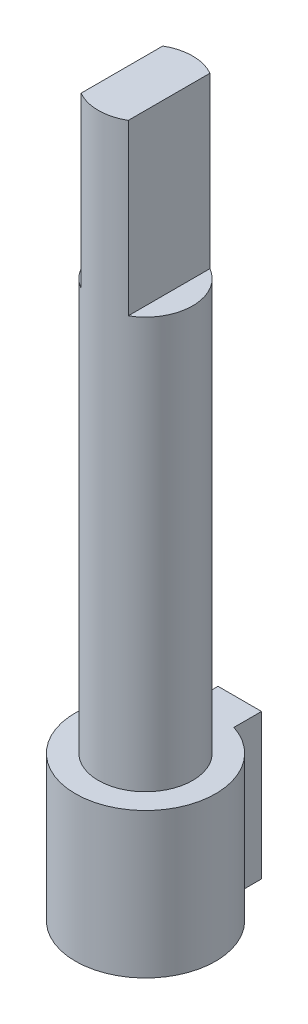
from build123d import *

# Parameters (mm, degrees)
SKETCH1_R           = 3
SKETCH1_W           = 2
SKETCH1_H           = 1.17
BOSS_EXTRUDE1_DEPTH = 30
SKETCH2_R           = 6.166150273
SKETCH2_R_2         = 1.95
CUT_EXTRUDE1_DEPTH  = 22
CUT_EXTRUDE2_DEPTH  = 7
CUT_EXTRUDE3_DEPTH  = 100
SKETCH5_R           = 1.95
CUT_EXTRUDE4_DEPTH  = 2


with BuildPart() as part:
    # Sketch1 → Boss-Extrude1 (new body)
    with BuildSketch(Plane(origin=(0, 0, 0), x_dir=(1, 0, 0), z_dir=(0, 1, 0))):
        Circle(SKETCH1_R)
        with Locations((0, 3.413427125)):
            Rectangle(SKETCH1_W, SKETCH1_H)
    extrude(amount=BOSS_EXTRUDE1_DEPTH)

    # Sketch2 → Cut-Extrude1 (cut)
    with BuildSketch(Plane(origin=(0, 30, 0), x_dir=(1, 0, 0), z_dir=(0, 1, 0))):
        Circle(SKETCH2_R)
        Circle(SKETCH2_R_2, mode=Mode.SUBTRACT)
    extrude(amount=-CUT_EXTRUDE1_DEPTH, mode=Mode.SUBTRACT)

    # Sketch3 → Cut-Extrude2 (cut)
    with BuildSketch(Plane(origin=(0, 30, 0), x_dir=(1, 0, 0), z_dir=(0, 1, 0))):
        with BuildLine():
            Line((-0.975, 1.688749537), (-0.975, -1.688749537))
            ThreePointArc((-0.975, -1.688749537), (-1.95, 0), (-0.975, 1.688749537))
        make_face()
        with BuildLine():
            Line((0.975, 1.688749537), (0.975, -1.688749537))
            ThreePointArc((0.975, -1.688749537), (1.95, 0), (0.975, 1.688749537))
        make_face()
    extrude(amount=-CUT_EXTRUDE2_DEPTH, mode=Mode.SUBTRACT)

    # Sketch4 → Cut-Extrude3 (cut)
    with BuildSketch(Plane.XZ):
        with BuildLine():
            Line((-1, -3.998427125), (1, -3.998427125))
            Line((1, -3.998427125), (1, -2.828427125))
            ThreePointArc((1, -2.828427125), (0, 3), (-1, -2.828427125))
            Line((-1, -2.828427125), (-1, -3.998427125))
        make_face()
        with BuildLine():
            Line((-0.9, -2.75680975), (-0.9, -3.898427125))
            Line((-0.9, -3.898427125), (0.9, -3.898427125))
            Line((0.9, -3.898427125), (0.9, -2.75680975))
            ThreePointArc((0.9, -2.75680975), (0, 2.9), (-0.9, -2.75680975))
        make_face(mode=Mode.SUBTRACT)
    extrude(amount=-CUT_EXTRUDE3_DEPTH, mode=Mode.SUBTRACT)

    # Sketch5 → Cut-Extrude4 (cut)
    with BuildSketch(Plane(origin=(0, 8, 0), x_dir=(1, 0, 0), z_dir=(0, 1, 0))):
        with BuildLine():
            Line((-2.76006086, 0.889979801), (-1.708873277, 4.14998829))
            Line((-1.708873277, 4.14998829), (2.174929625, 4.14998829))
            Line((2.174929625, 4.14998829), (2.48458984, 1.495597984))
            ThreePointArc((2.48458984, 1.495597984), (0.332662617, -2.880856745), (-2.76006086, 0.889979801))
        make_face()
        Circle(SKETCH5_R, mode=Mode.SUBTRACT)
    extrude(amount=-CUT_EXTRUDE4_DEPTH, mode=Mode.SUBTRACT)


solid = part.part
